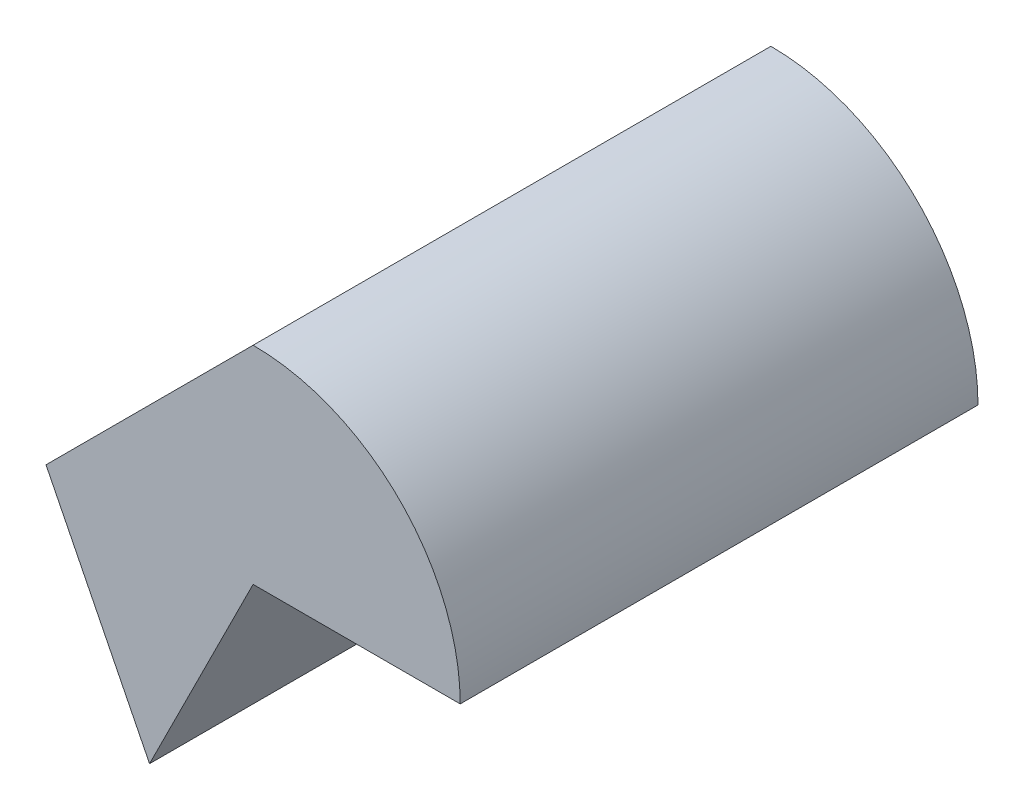
from build123d import *

# Parameters (mm, degrees)
BOSS_EXTRUDE1_DEPTH = 25


with BuildPart() as part:
    # Sketch1 → Boss-Extrude1 (new body)
    with BuildSketch(Plane.XY):
        with BuildLine():
            Line((-10, 0), (0, 10))
            ThreePointArc((0, 10), (7.071067812, 7.071067812), (10, 0))
            Line((10, 0), (0, 0))
            Line((0, 0), (-5, -10))
            Line((-5, -10), (-10, 0))
        make_face()
    extrude(amount=BOSS_EXTRUDE1_DEPTH)


solid = part.part
